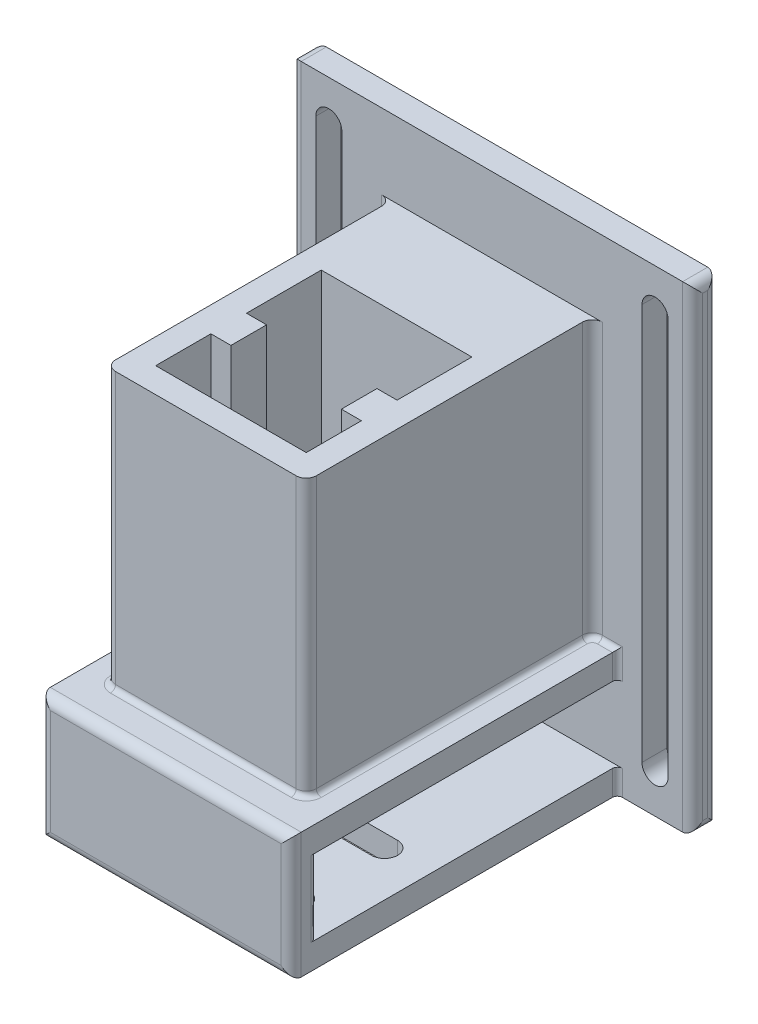
from build123d import *

# Parameters (mm, degrees)
SKETCH_1_W           = 40
SKETCH_1_H           = 60
EXTRUDE_1_DEPTH      = 55
CUT_EXTRUDE_1_DEPTH  = 50
SKETCH_6_W           = 50
SKETCH_6_H           = 70
EXTRUDE_2_DEPTH      = 25
SKETCH_7_W           = 60
SKETCH_7_H           = 15
CUT_EXTRUDE_2_DEPTH  = 51
CUT_EXTRUDE_3_REACH  = 82
SKETCH_10_W          = 80
SKETCH_10_H          = 5
EXTRUDE_3_DEPTH      = 70
EXTRUDE_3_DEPTH_BACK = 25
CUT_EXTRUDE_4_REACH  = 72
FILLET_1_R           = 2
FILLET_2_R           = 1
FILLET_3_R           = 1


with BuildPart() as part:
    # 草图1 → 凸台-拉伸1 (new body)
    with BuildSketch(Plane(origin=(0, 0, 0), x_dir=(1, 0, 0), z_dir=(0, 1, 0))):
        with Locations((0, 10)):
            Rectangle(SKETCH_1_W, SKETCH_1_H)
    extrude(amount=EXTRUDE_1_DEPTH)

    # 草图2 → 切除-拉伸1 (cut)
    with BuildSketch(Plane(origin=(0, 55, 0), x_dir=(1, 0, 0), z_dir=(0, 1, 0))):
        Polygon((-15, 15), (-15, 3.1), (-11, 3.1), (-11, -4), (-15, -4), (-15, -15), (15, -15), (15, -4), (11, -4), (11, 3.1), (15, 3.1), (15, 15), (15, 18), (-15, 18), align=None)
    extrude(amount=-CUT_EXTRUDE_1_DEPTH, mode=Mode.SUBTRACT)

    # 草图6 → 凸台-拉伸2 (add)
    with BuildSketch(Plane(origin=(0, 0, 0), x_dir=(-1, 0, 0), z_dir=(0, -1, 0))):
        with Locations((0, 7)):
            Rectangle(SKETCH_6_W, SKETCH_6_H)
    extrude(amount=EXTRUDE_2_DEPTH)

    # 草图7 → 切除-拉伸2 (cut, through all)
    with BuildSketch(Plane(origin=(25, 0, 0), x_dir=(0, 0, -1), z_dir=(1, 0, 0))):
        with Locations((7, -12.5)):
            Rectangle(SKETCH_7_W, SKETCH_7_H)
    extrude(amount=-CUT_EXTRUDE_2_DEPTH, mode=Mode.SUBTRACT)

    # 草图8 → 切除-拉伸3 (cut, up to next)
    with BuildSketch(Plane.XZ.offset(25), mode=Mode.PRIVATE) as cut_extrude_3_sk1:
        with BuildLine():
            Line((-16, 20.6), (16, 20.6))
            ThreePointArc((16, 20.6), (18.6, 18), (16, 15.4))
            Line((16, 15.4), (-16, 15.4))
            ThreePointArc((-16, 15.4), (-18.6, 18), (-16, 20.6))
        make_face()
    cut_extrude_3_tool1 = extrude(cut_extrude_3_sk1.sketch, amount=-CUT_EXTRUDE_3_REACH, mode=Mode.PRIVATE) & part.part
    add(cut_extrude_3_tool1.solids().sort_by_distance((0, -25, 18))[0], mode=Mode.SUBTRACT)
    # 草图8 → 切除-拉伸3 (cut, up to next)
    with BuildSketch(Plane.XZ.offset(25), mode=Mode.PRIVATE) as cut_extrude_3_sk2:
        with BuildLine():
            Line((-16, 3), (16, 3))
            ThreePointArc((16, 3), (18.6, 0.4), (16, -2.2))
            Line((16, -2.2), (-16, -2.2))
            ThreePointArc((-16, -2.2), (-18.6, 0.4), (-16, 3))
        make_face()
    cut_extrude_3_tool2 = extrude(cut_extrude_3_sk2.sketch, amount=-CUT_EXTRUDE_3_REACH, mode=Mode.PRIVATE) & part.part
    add(cut_extrude_3_tool2.solids().sort_by_distance((0, -25, 0.4))[0], mode=Mode.SUBTRACT)

    # 草图10 → 凸台-拉伸3 (add, two sides)
    with BuildSketch(Plane(origin=(0, 0, 0), x_dir=(1, 0, 0), z_dir=(0, 1, 0))) as extrude_3_sk:
        with Locations((0, 39.5)):
            Rectangle(SKETCH_10_W, SKETCH_10_H)
    extrude(amount=EXTRUDE_3_DEPTH)
    extrude(extrude_3_sk.sketch, amount=-EXTRUDE_3_DEPTH_BACK)

    # 草图11 → 切除-拉伸4 (cut, up to next)
    with BuildSketch(Plane(origin=(0, 0, -42), x_dir=(-1, 0, 0), z_dir=(0, 0, -1)), mode=Mode.PRIVATE) as cut_extrude_4_sk1:
        with BuildLine():
            Line((-29.9, 62), (-29.9, -17))
            ThreePointArc((-29.9, -17), (-32.5, -19.6), (-35.1, -17))
            Line((-35.1, -17), (-35.1, 62))
            ThreePointArc((-35.1, 62), (-32.5, 64.6), (-29.9, 62))
        make_face()
    cut_extrude_4_tool1 = extrude(cut_extrude_4_sk1.sketch, amount=-CUT_EXTRUDE_4_REACH, mode=Mode.PRIVATE) & part.part
    add(cut_extrude_4_tool1.solids().sort_by_distance((32.5, 22.5, -42))[0], mode=Mode.SUBTRACT)
    # 草图11 → 切除-拉伸4 (cut, up to next)
    with BuildSketch(Plane(origin=(0, 0, -42), x_dir=(-1, 0, 0), z_dir=(0, 0, -1)), mode=Mode.PRIVATE) as cut_extrude_4_sk2:
        with BuildLine():
            Line((29.9, 62), (29.9, -17))
            ThreePointArc((29.9, -17), (32.5, -19.6), (35.1, -17))
            Line((35.1, -17), (35.1, 62))
            ThreePointArc((35.1, 62), (32.5, 64.6), (29.9, 62))
        make_face()
    cut_extrude_4_tool2 = extrude(cut_extrude_4_sk2.sketch, amount=-CUT_EXTRUDE_4_REACH, mode=Mode.PRIVATE) & part.part
    add(cut_extrude_4_tool2.solids().sort_by_distance((-32.5, 22.5, -42))[0], mode=Mode.SUBTRACT)

    # 圆角1
    fillet_1_edges = [part.edges().sort_by_distance(p)[0] for p in [
        (-40, 22.5, -42),
        (40, 22.5, -37),
        (20, 27.5, -37),
        (-20, 27.5, -37),
        (-40, 22.5, -37),
        (-40, -25, -39.5),
        (40, 22.5, -42),
        (40, -25, -39.5),
        (-40, 70, -39.5),
        (40, 70, -39.5),
        (0, 0, 28),
        (25, -12.5, 28),
        (-25, -12.5, 28),
        (0, -25, 28),
        (20, 27.5, 20),
        (-20, 27.5, 20),
    ]]
    fillet(fillet_1_edges, radius=FILLET_1_R)

    # 圆角2
    fillet_2_edges = [part.edges().sort_by_distance(p)[0] for p in [
        (-23.5, 0, -37),
        (23.5, 0, -37),
        (20, 0, -8.5),
        (0, 0, 20),
        (-20, 0, -8.5),
        (-20.585786438, 0, -36.414213562),
        (20.585786438, 0, -36.414213562),
        (19.414213562, 0, 19.414213562),
        (-19.414213562, 0, 19.414213562),
    ]]
    fillet(fillet_2_edges, radius=FILLET_2_R)

    # 圆角3
    fillet_3_edges = [part.edges().sort_by_distance(p)[0] for p in [
        (25, -12.5, 23),
        (-25, -12.5, 23),
        (-25, -22.5, -37),
        (-25, -2.5, -37),
        (25, -22.5, -37),
        (25, -2.5, -37),
    ]]
    fillet(fillet_3_edges, radius=FILLET_3_R)


solid = part.part
